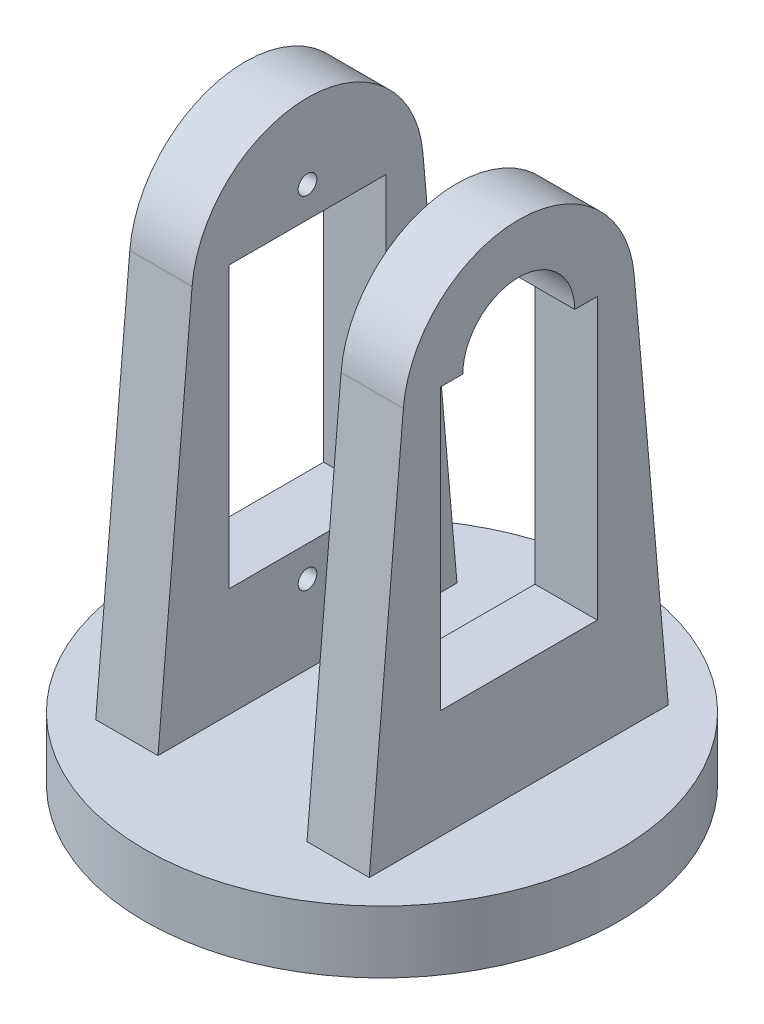
from build123d import *

# Parameters (mm, degrees)
SKETCH1_R           = 19.05
SKETCH1_R_2         = 2.75
BOSS_EXTRUDE1_DEPTH = 5
CUT_EXTRUDE1_DEPTH  = 4.1
SKETCH5_W           = 12.6
SKETCH5_H           = 22.5
BOSS_EXTRUDE2_DEPTH = 5
SKETCH6_R           = 0.75
CUT_EXTRUDE2_DEPTH  = 5
CUT_EXTRUDE3_DEPTH  = 5


with BuildPart() as part:
    # Sketch1 → Boss-Extrude1 (new body)
    with BuildSketch(Plane(origin=(0, 0, 0), x_dir=(1, 0, 0), z_dir=(0, 1, 0))):
        Circle(SKETCH1_R)
        Circle(SKETCH1_R_2, mode=Mode.SUBTRACT)
    extrude(amount=BOSS_EXTRUDE1_DEPTH)

    # Sketch4 → Cut-Extrude1 (cut)
    with BuildSketch(Plane(origin=(0, 0, 0), x_dir=(1, 0, 0), z_dir=(0, 1, 0))):
        Polygon((0, 4.641896164), (-4.02, 2.320948082), (-4.02, -2.320948082), (0, -4.641896164), (4.02, -2.320948082), (4.02, 2.320948082), align=None)
    extrude(amount=CUT_EXTRUDE1_DEPTH, mode=Mode.SUBTRACT)

    # Sketch5 → Boss-Extrude2 (add)
    with BuildSketch(Plane.ZY.offset(10.98)):
        with BuildLine():
            Line((-12, 5), (12, 5))
            Line((12, 5), (9.265979265, 36.25))
            ThreePointArc((9.265979265, 36.25), (0, 44.740705658), (-9.265979265, 36.25))
            Line((-9.265979265, 36.25), (-12, 5))
        make_face()
        with Locations((0, 25)):
            Rectangle(SKETCH5_W, SKETCH5_H, mode=Mode.SUBTRACT)
    boss_extrude2 = extrude(amount=-BOSS_EXTRUDE2_DEPTH)

    # Mirror1: Boss-Extrude2 across plane
    add(boss_extrude2.mirror(Plane(origin=(0, 0, 0), x_dir=(0, 0, 1), z_dir=(1, 0, 0))))

    # Sketch6 → Cut-Extrude2 (cut)
    with BuildSketch(Plane.ZY.offset(10.98)):
        with Locations((0, 38.715999834)):
            Circle(SKETCH6_R)
        with Locations((0, 11.284000166)):
            Circle(SKETCH6_R)
    extrude(amount=-CUT_EXTRUDE2_DEPTH, mode=Mode.SUBTRACT)

    # Sketch7 → Cut-Extrude3 (cut)
    with BuildSketch(Plane.ZY.offset(-5.98)):
        with BuildLine():
            Line((-4.490705658, 36.25), (4.490705658, 36.25))
            ThreePointArc((4.490705658, 36.25), (0, 40.740705658), (-4.490705658, 36.25))
        make_face()
    extrude(amount=-CUT_EXTRUDE3_DEPTH, mode=Mode.SUBTRACT)


solid = part.part
